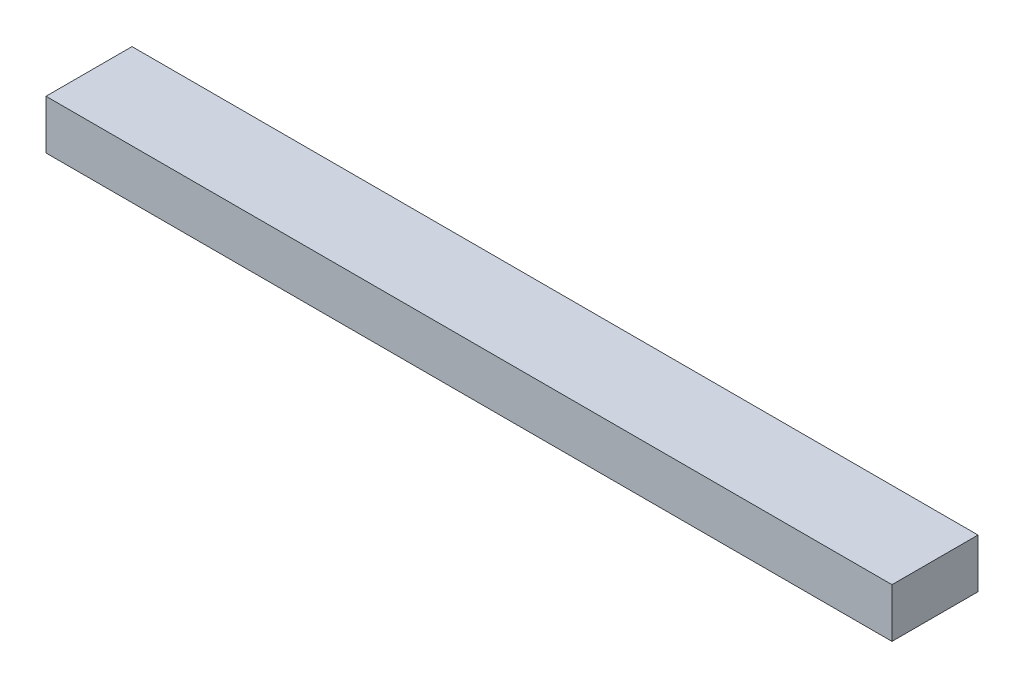
from build123d import *

# Parameters (mm, degrees)
SKETCH1_W           = 874.395
SKETCH1_H           = 88.9
BOSS_EXTRUDE1_DEPTH = 25.4


with BuildPart() as part:
    # Sketch1 → Boss-Extrude1 (new body, symmetric)
    with BuildSketch(Plane(origin=(0, 0, 0), x_dir=(1, 0, 0), z_dir=(0, 1, 0))):
        Rectangle(SKETCH1_W, SKETCH1_H)
    extrude(amount=BOSS_EXTRUDE1_DEPTH, both=True)


solid = part.part
